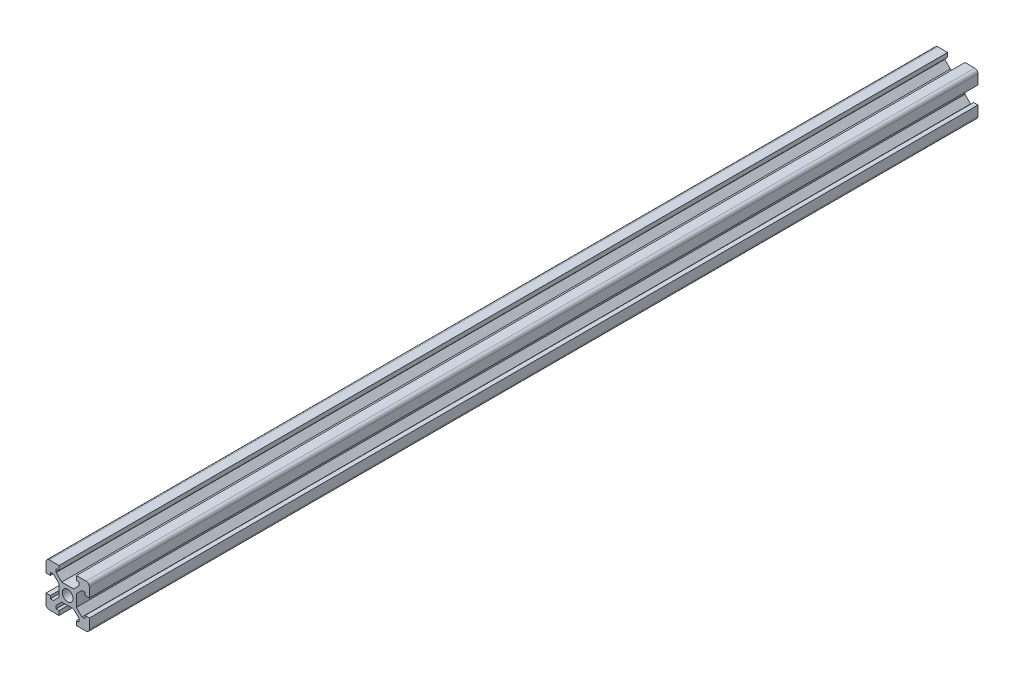
from build123d import *

# Parameters (mm, degrees)
SKETCH_1_R      = 2.5
EXTRUDE_1_DEPTH = 410
FILLET_1_R      = 1.5


with BuildPart() as part:
    # Эскиз1 → Бобышка-Вытянуть1 (new body)
    with BuildSketch(Plane.XY):
        Polygon((14, 20), (20, 20), (20, 14), (18, 14), (18, 15.3), (16.572792206, 15.3), (14, 12.727207794), (14, 7.272792206), (16.572792206, 4.7), (18, 4.7), (18, 6), (20, 6), (20, 0), (14, 0), (14, 2), (15.3, 2), (15.3, 3.427207794), (12.684044775, 6), (7.272792206, 6), (4.7, 3.427207794), (4.7, 2), (6, 2), (6, 0), (0, 0), (0, 6), (2, 6), (2, 4.7), (3.427207794, 4.7), (6, 7.272792206), (6, 12.727207794), (3.427207794, 15.3), (2, 15.3), (2, 14), (0, 14), (0, 20), (6, 20), (6, 18), (4.7, 18), (4.7, 16.572792206), (7.272792206, 14), (12.727207794, 14), (15.3, 16.572792206), (15.3, 18), (14, 18), align=None)
        with Locations((10, 10)):
            Circle(SKETCH_1_R, mode=Mode.SUBTRACT)
    extrude(amount=EXTRUDE_1_DEPTH)

    # Скругление1
    fillet_1_edges = [part.edges().sort_by_distance(p)[0] for p in [
        (0, 20, 205),
        (20, 20, 205),
        (20, 0, 205),
        (0, 0, 205),
    ]]
    fillet(fillet_1_edges, radius=FILLET_1_R)


solid = part.part
